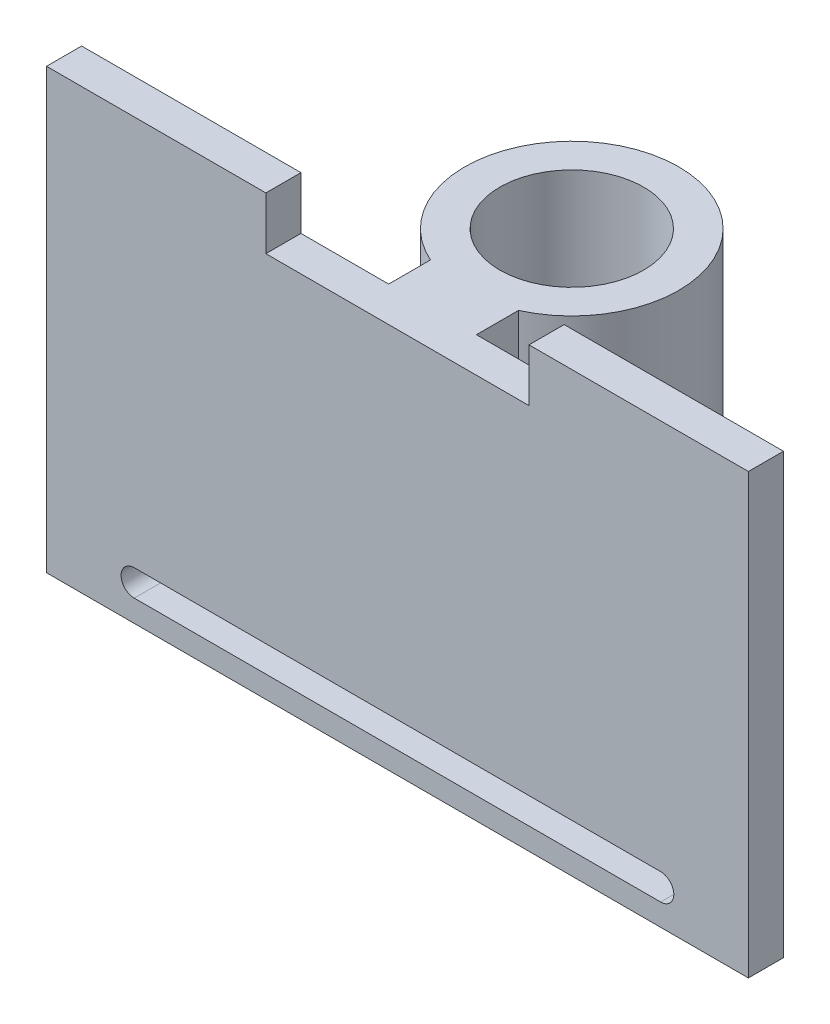
from build123d import *

# Parameters (mm, degrees)
EXTRUDE_1_DEPTH = 2
SKETCH_2_R      = 4.1
EXTRUDE_2_DEPTH = 15


with BuildPart() as part:
    # 草图1 → 凸台-拉伸1 (new body)
    with BuildSketch(Plane.XY):
        Polygon((-12.668616293, 22.288540635), (-0.168616293, 22.288540635), (-0.168616293, 19.288540635), (14.831383707, 19.288540635), (14.831383707, 22.288540635), (27.331383707, 22.288540635), (27.331383707, -2.711459365), (-12.668616293, -2.711459365), align=None)
        with BuildLine():
            Line((-7.668616293, 0.038540635), (22.331383707, 0.038540635))
            ThreePointArc((22.331383707, 0.038540635), (23.081383707, -0.711459365), (22.331383707, -1.461459365))
            Line((22.331383707, -1.461459365), (-7.668616293, -1.461459365))
            ThreePointArc((-7.668616293, -1.461459365), (-8.418616293, -0.711459365), (-7.668616293, 0.038540635))
        make_face(mode=Mode.SUBTRACT)
    extrude(amount=EXTRUDE_1_DEPTH)

    # 草图2 → 凸台-拉伸2 (add)
    with BuildSketch(Plane(origin=(0, 19.288540635, 0), x_dir=(1, 0, 0), z_dir=(0, 1, 0))):
        with BuildLine():
            Line((4.831383707, 2.381058819), (4.831383707, 0))
            Line((4.831383707, 0), (9.831383707, 0))
            Line((9.831383707, 0), (9.831383707, 2.399323324))
            ThreePointArc((9.831383707, 2.399323324), (7.288775956, 14.054276854), (4.831383707, 2.381058819))
        make_face()
        with Locations((7.311058504, 7.954317551)):
            Circle(SKETCH_2_R, mode=Mode.SUBTRACT)
    extrude(amount=-EXTRUDE_2_DEPTH)


solid = part.part
